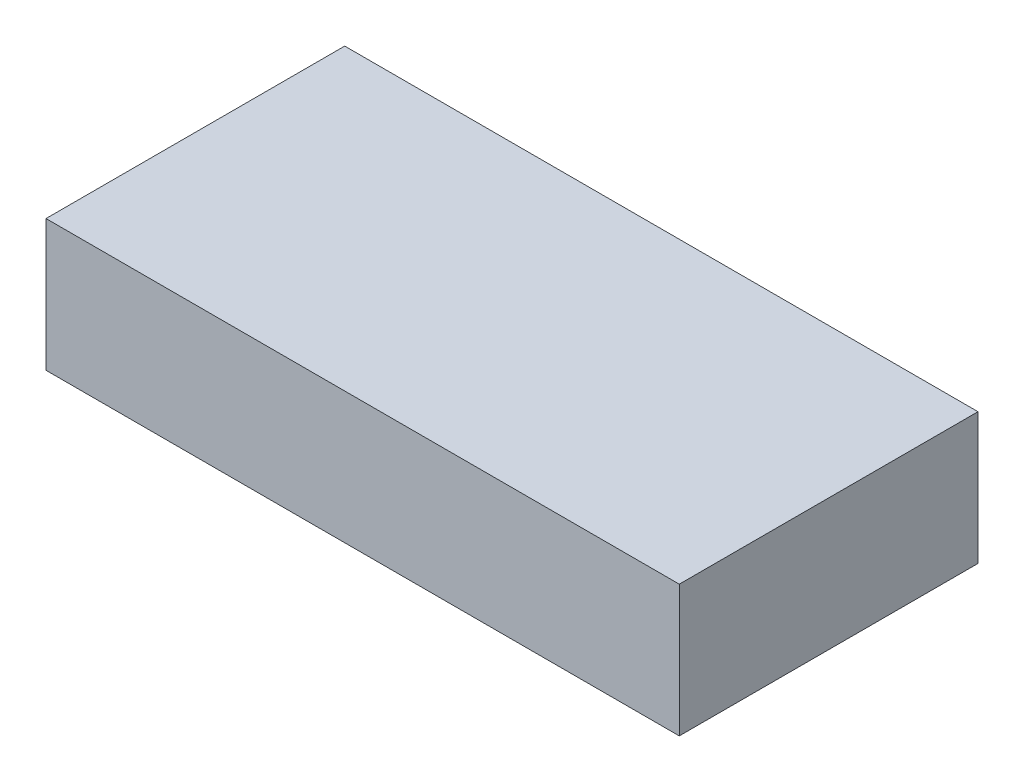
from build123d import *

# Parameters (mm, degrees)
SKETCH1_W           = 53
SKETCH1_H           = 25
BOSS_EXTRUDE1_DEPTH = 11


with BuildPart() as part:
    # Sketch1 → Boss-Extrude1 (new body)
    with BuildSketch(Plane(origin=(0, 0, 0), x_dir=(1, 0, 0), z_dir=(0, 1, 0))):
        with Locations((26.5, -12.5)):
            Rectangle(SKETCH1_W, SKETCH1_H)
    extrude(amount=BOSS_EXTRUDE1_DEPTH)


solid = part.part
